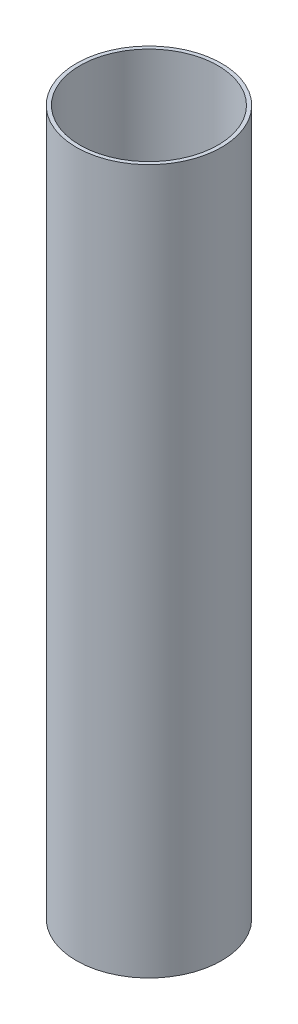
from build123d import *

# Parameters (mm, degrees)
SKETCH1_R           = 93.6625
SKETCH1_R_2         = 88.9
BOSS_EXTRUDE1_DEPTH = 453.84466


with BuildPart() as part:
    # Sketch1 → Boss-Extrude1 (new body, symmetric)
    with BuildSketch(Plane(origin=(0, 0, 0), x_dir=(1, 0, 0), z_dir=(0, 1, 0))):
        Circle(SKETCH1_R)
        Circle(SKETCH1_R_2, mode=Mode.SUBTRACT)
    extrude(amount=BOSS_EXTRUDE1_DEPTH, both=True)


solid = part.part
